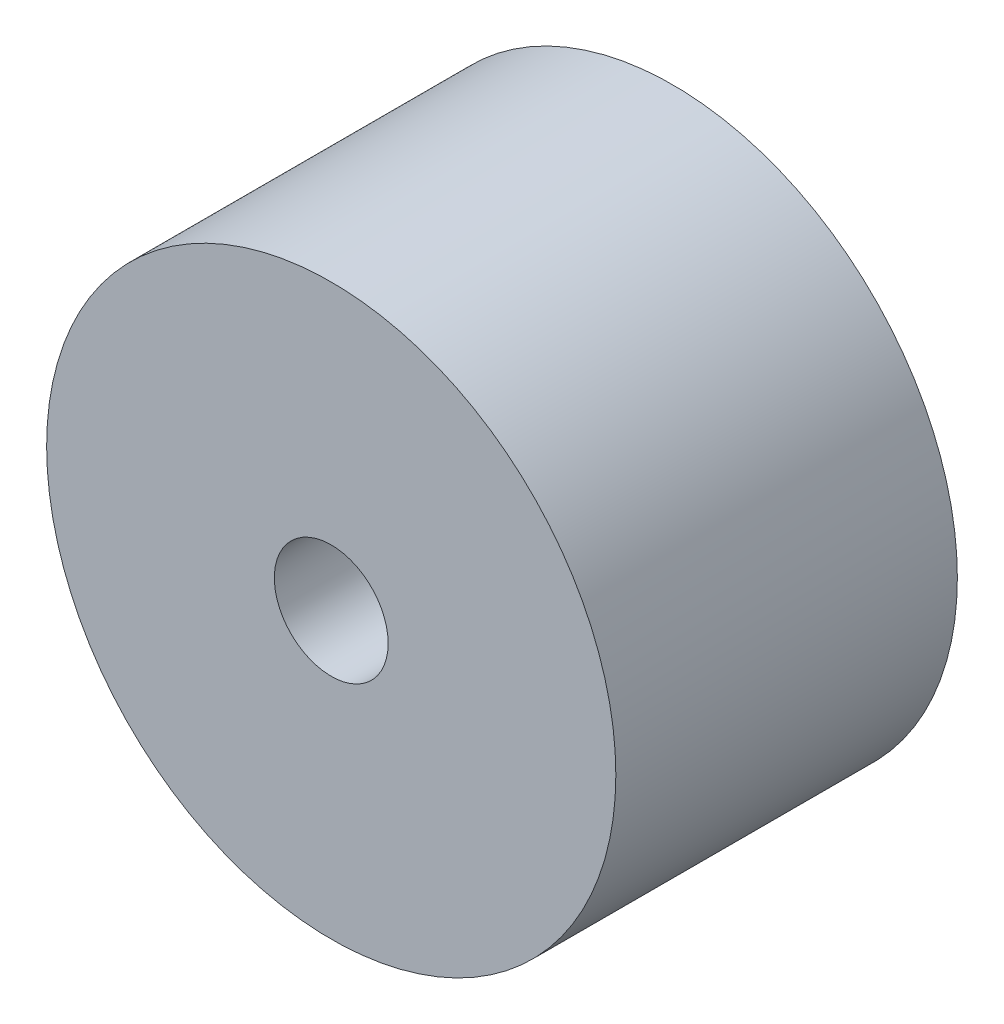
from build123d import *

# Parameters (mm, degrees)
ESQUISSE1_R          = 2.5
ESQUISSE1_R_2        = 0.5
BASE_EXTRUSION_DEPTH = 3


with BuildPart() as part:
    # Esquisse1 → Base-Extrusion (new body)
    with BuildSketch(Plane.XY):
        Circle(ESQUISSE1_R)
        Circle(ESQUISSE1_R_2, mode=Mode.SUBTRACT)
    extrude(amount=BASE_EXTRUSION_DEPTH)


solid = part.part
